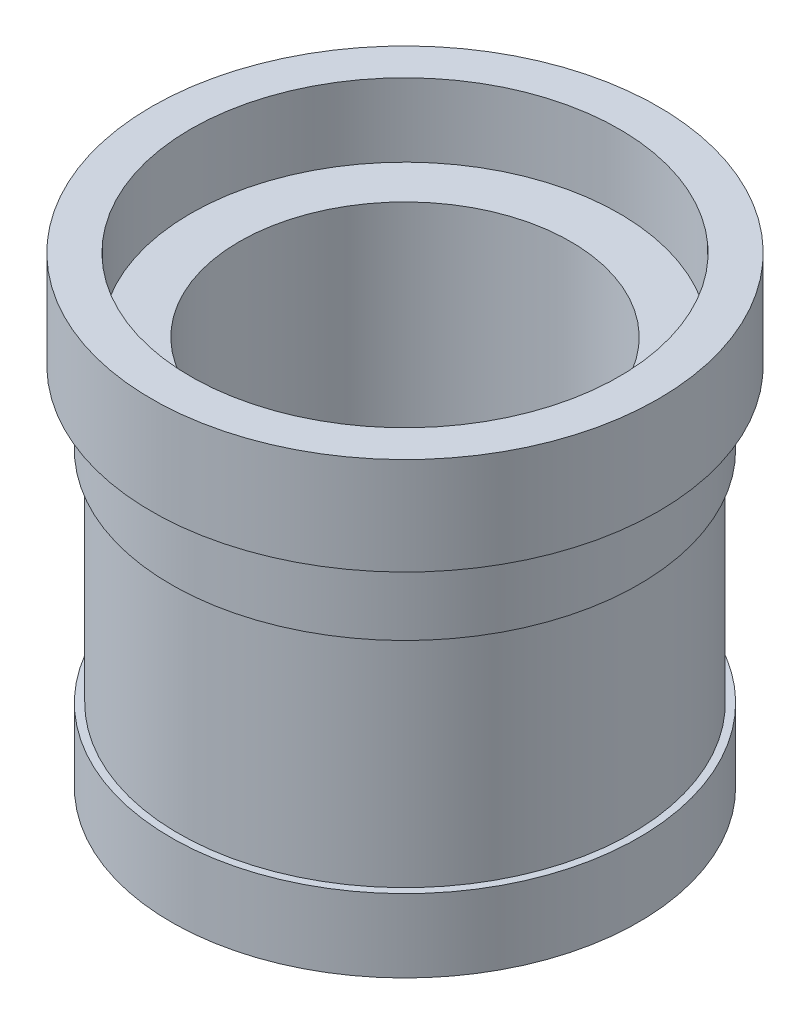
from build123d import *


with BuildPart() as part:
    # Sketch1 → Revolve1 (revolve)
    with BuildSketch(Plane.XY):
        Polygon((34, 0), (48, 0), (48, 15), (46.5, 15), (46.5, 60), (48, 60), (48, 75), (52, 75), (52, 95), (44, 95), (44, 80), (34, 80), align=None)
    revolve(axis=Axis((0, 74.800741628, 0), (0, -1, 0)))


solid = part.part
